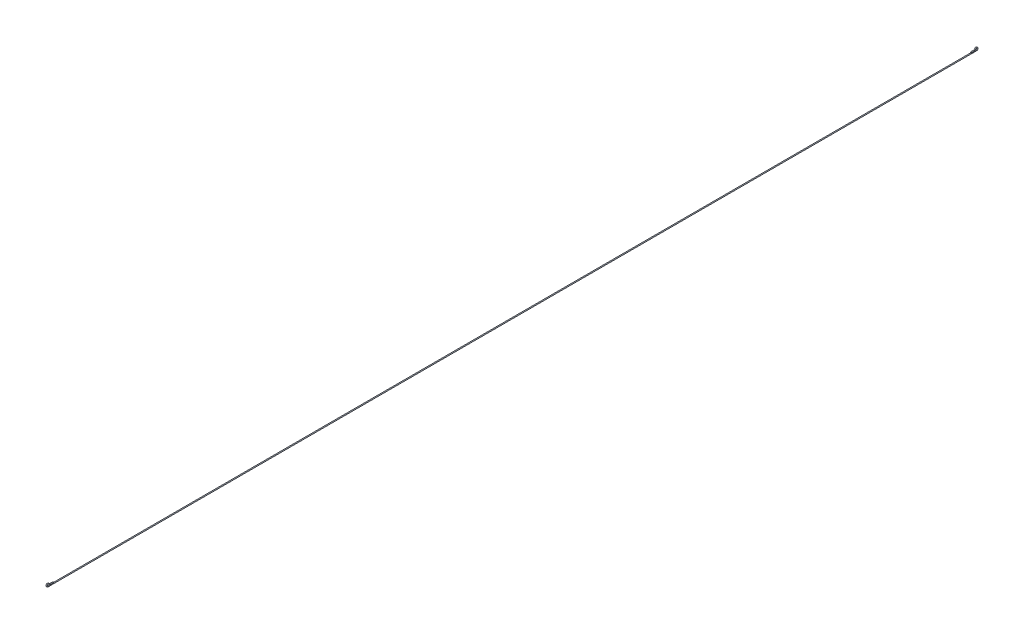
from build123d import *

# Parameters (mm, degrees)
SKETCH1_R = 1.5


with BuildPart() as part:
    # Sweep1: sweep along a path in Sketch2
    with BuildLine(Plane(origin=(0, 0, 0), x_dir=(0, 0, -1), z_dir=(1, 0, 0))) as sweep1_path:
        Line((1555.583801513, -3), (-17.416198487, -3))
        ThreePointArc((-17.416198487, -3), (-20.732823277, 3.236067977), (-13.708099244, 2.5))
        ThreePointArc((-13.708099244, 2.5), (-12.236067977, 0.68337521), (-10, 0))
        Line((-10, 0), (0, 0))
    # Sketch1 → Sweep1 (sweep)
    with BuildSketch(Plane.XY):
        Circle(SKETCH1_R)
    sweep1 = sweep(path=sweep1_path.line)

    # Mirror1: Sweep1 across plane
    add(sweep1.mirror(Plane(origin=(0, -3, -1555.583801513), x_dir=(1, 0, 0), z_dir=(0, 0, -1))))


solid = part.part
